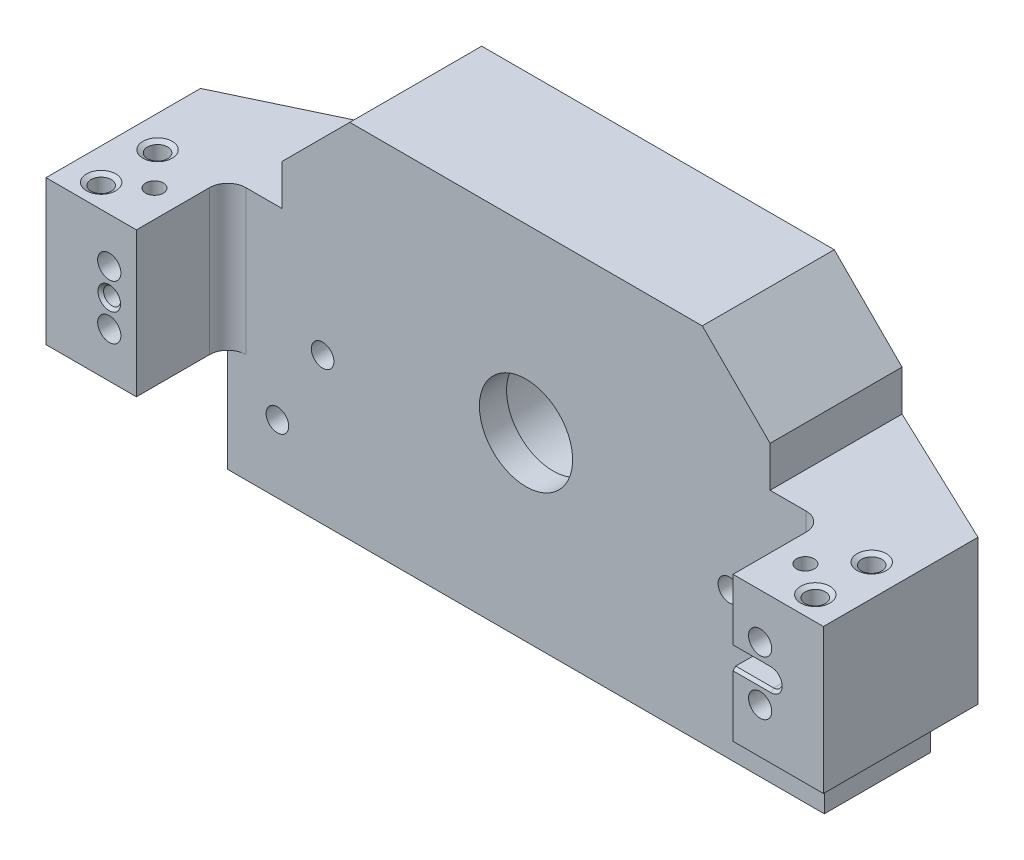
from build123d import *

# Parameters (mm, degrees)
EXTRUDE1_DEPTH                                 = 20.32
EXTRUDE2_DEPTH                                 = 20.32
SKETCH24_W                                     = 68.58
SKETCH24_H                                     = 18.542
EXTRUDE3_DEPTH                                 = 15.24
EXTRUDE4_DEPTH                                 = 15.24
SKETCH38_R                                     = 17.78
SPHERICAL_WASHER_CENTER_RELIEF_DEPTH           = 0.762
TAPPED_HOLE_FOR_1_4_20_HELICOIL_AT_2_COUNT     = 2
TAPPED_HOLE_FOR_1_4_20_HELICOIL_AT_2_PITCH     = 57.15
SKETCH30_R                                     = 1.59512
PIN_SLOT_HOLES_DEPTH                           = 9.525
F_4_CLEARANCE_HOLE1_D                          = 3.175
F_4_CLEARANCE_HOLE2_D                          = 3.175
CBORE_FOR_4_SOCKET_HEAD_CAP_SCREW1_D           = 3.2639
CBORE_FOR_4_SOCKET_HEAD_CAP_SCREW1_CBORE_D     = 5.9436
CBORE_FOR_4_SOCKET_HEAD_CAP_SCREW1_CBORE_DEPTH = 18.2372
F_40_0_098_DIAMETER_HOLE0_D                    = 2.4892
F_4_40_TAPPED_HOLE1_AT_2_COUNT                 = 2
F_4_40_TAPPED_HOLE1_AT_2_PITCH                 = 7.9248
F_4_40_TAPPED_HOLE1_AT_3_COUNT                 = 2
F_4_40_TAPPED_HOLE1_AT_3_PITCH                 = 100.64249279
F_4_40_TAPPED_HOLE1_AT_4_COUNT                 = 2
F_4_40_TAPPED_HOLE1_AT_4_PITCH                 = 100.33
CHAMFER1_SIZE                                  = 9.525
FILLET1_R                                      = 2.54
CHAMFER2_SIZE                                  = 0.9906
F_4_CLEARANCE_HOLE3_D                          = 2.3876
F_4_CLEARANCE_HOLE3_DEPTH                      = 6.35
F_4_CLEARANCE_HOLE3_CSINK_D                    = 3.175
F_4_CLEARANCE_HOLE3_CSINK_ANGLE                = 90
F_4_CLEARANCE_HOLE3_TIP                        = 0.717307407
EXTRUDE5_DEPTH                                 = 6.35
CHAMFER3_SIZE                                  = 0.381


with BuildPart() as part:
    # Sketch2 → Extrude1 (new body)
    with BuildSketch(Plane(origin=(0, 0, 0), x_dir=(1, 0, 0), z_dir=(0, 1, 0))):
        Polygon((-54.61, -12.7), (-54.61, 9.017), (-34.29, 9.017), (-34.29, 18.669), (34.29, 18.669), (34.29, 9.017), (54.61, 9.017), (54.61, -12.7), (41.91, -12.7), (41.91, 0.127), (-41.91, 0.127), (-41.91, -12.7), align=None)
    extrude(amount=EXTRUDE1_DEPTH)

    # Sketch19 → Extrude2 (add)
    with BuildSketch(Plane(origin=(0, 20.32, 0), x_dir=(1, 0, 0), z_dir=(0, 1, 0))):
        Polygon((54.61, 9.017), (34.29, 9.017), (34.29, 18.669), align=None)
        Polygon((-34.29, 18.669), (-34.29, 9.017), (-54.61, 9.017), align=None)
    extrude(amount=-EXTRUDE2_DEPTH)

    # Sketch24 → Extrude3 (add)
    with BuildSketch(Plane(origin=(0, 20.32, 0), x_dir=(1, 0, 0), z_dir=(0, 1, 0))):
        with Locations((0, 9.398)):
            Rectangle(SKETCH24_W, SKETCH24_H)
    extrude(amount=EXTRUDE3_DEPTH)

    # Sketch25 → Extrude4 (add)
    with BuildSketch(Plane.XZ):
        Polygon((-34.29, -18.669), (34.29, -18.669), (41.91, -15.0495), (41.91, -0.127), (-41.91, -0.127), (-41.91, -15.0495), align=None)
    extrude(amount=EXTRUDE4_DEPTH)

    # Sketch38 → Spherical washer Center Relief (cut)
    with BuildSketch(Plane(origin=(0, 0, -18.669), x_dir=(-1, 0, 0), z_dir=(0, 0, -1))):
        with Locations((0, 10.16)):
            Circle(SKETCH38_R)
    extrude(amount=-SPHERICAL_WASHER_CENTER_RELIEF_DEPTH, mode=Mode.SUBTRACT)

    # Sketch26 → Tapped Hole For 1/4-20 Helicoil (revolve, cut)
    with BuildSketch(Plane(origin=(28.575, -15.24, -6.35), x_dir=(0, 0, -1), z_dir=(1, 0, 0))):
        Polygon((0, 0), (0, 22.603827343), (3.3782, 20.574), (3.3782, 11.684), (4.04749, 11.684), (4.04749, 0.01651), (4.064, 0), align=None)
    tapped_hole_for_1_4_20_helicoil = revolve(axis=Axis((28.575, -21.59, -6.35), (0, 1, 0)), mode=Mode.SUBTRACT)

    # Tapped Hole For 1/4-20 Helicoil at 2: Tapped Hole For 1/4-20 Helicoil ×2
    with Locations(*[(-i * TAPPED_HOLE_FOR_1_4_20_HELICOIL_AT_2_PITCH, 0, 0) for i in range(1, TAPPED_HOLE_FOR_1_4_20_HELICOIL_AT_2_COUNT)]):
        add(tapped_hole_for_1_4_20_helicoil, mode=Mode.SUBTRACT)

    # Sketch30 → Pin & Slot Holes (cut)
    with BuildSketch(Plane.XZ.offset(15.24)):
        with Locations(Location((34.925, -13.97, 0), (0, 0, 270))):  # turned: the seam where the file's is
            Circle(SKETCH30_R)
        with BuildLine():
            Line((-33.3375, -15.56512), (-36.5125, -15.56512))
            ThreePointArc((-36.5125, -15.56512), (-38.10762, -13.97), (-36.5125, -12.37488))
            Line((-36.5125, -12.37488), (-33.3375, -12.37488))
            ThreePointArc((-33.3375, -12.37488), (-31.74238, -13.97), (-33.3375, -15.56512))
        make_face()
    extrude(amount=-PIN_SLOT_HOLES_DEPTH, mode=Mode.SUBTRACT)

    # #4 Clearance Hole1 (through all)
    with Locations(Plane(origin=(0, 0, -18.669), x_dir=(-1, 0, 0), z_dir=(0, 0, -1))):
        with Locations((-28.575, 5.334), (28.575, 5.334)):
            Hole(F_4_CLEARANCE_HOLE1_D / 2)

    # #4 Clearance Hole2 (through all)
    with Locations(Plane(origin=(0, 0, -18.669), x_dir=(-1, 0, 0), z_dir=(0, 0, -1))):
        with Locations((-34.925, -5.715), (34.925, -5.715)):
            Hole(F_4_CLEARANCE_HOLE2_D / 2)

    # CBORE for #4 Socket Head Cap Screw1 (through all)
    with Locations(Plane(origin=(-10.402382087, -1.81948853, -18.669), x_dir=(-1, 0, 0), z_dir=(0, 0, -1))):
        with Locations((35.317617913, 8.16948853), (35.317617913, 15.78948853), (-56.122382087, 8.16948853), (-56.122382087, 15.78948853)):
            CounterBoreHole(CBORE_FOR_4_SOCKET_HEAD_CAP_SCREW1_D / 2, CBORE_FOR_4_SOCKET_HEAD_CAP_SCREW1_CBORE_D / 2, CBORE_FOR_4_SOCKET_HEAD_CAP_SCREW1_CBORE_DEPTH)

    # Sketch22 → Tapped Hole for 1/2-13  Helicoil1 (revolve, cut)
    with BuildSketch(Plane(origin=(0, 10.16, -18.669), x_dir=(0, 1, 0), z_dir=(1, 0, 0))):
        Polygon((0, 0), (0, 31.369), (8.30834, 31.369), (6.54812, 30.352736509), (6.54812, 14.732), (7.67334, 14.732), (7.67334, 0.366617421), (8.30834, 0), align=None)
    revolve(axis=Axis((0, 10.16, -25.019), (0, 0, 1)), mode=Mode.SUBTRACT)

    # #40 (0.098) Diameter Hole0 (through all)
    with Locations(Plane(origin=(0, 20.32, 0), x_dir=(-1, 0, 0), z_dir=(0, 1, 0))):
        with Locations((45.72, 6.35), (-45.72, 6.35)):
            Hole(F_40_0_098_DIAMETER_HOLE0_D / 2)

    # Sketch20 → #4-40 Tapped Hole1 (revolve, cut)
    with BuildSketch(Plane(origin=(-50.165, 20.32, 9.398), x_dir=(0, 0, 1), z_dir=(1, 0, 0))):
        Polygon((0, 0), (0, 20.32), (2.0574, 20.32), (1.4224, 19.953382579), (1.4224, 0.366617421), (2.0574, 0), align=None)
    f_4_40_tapped_hole1 = revolve(axis=Axis((-50.165, 26.67, 9.398), (0, -1, 0)), mode=Mode.SUBTRACT)

    # #4-40 Tapped Hole1 at 2: #4-40 Tapped Hole1 ×2
    with Locations(*[(0, 0, -i * F_4_40_TAPPED_HOLE1_AT_2_PITCH) for i in range(1, F_4_40_TAPPED_HOLE1_AT_2_COUNT)]):
        add(f_4_40_tapped_hole1, mode=Mode.SUBTRACT)

    # #4-40 Tapped Hole1 at 3: #4-40 Tapped Hole1 ×2
    with Locations(*[Vector(0.996895021, 0, -0.078742088) * (i * F_4_40_TAPPED_HOLE1_AT_3_PITCH) for i in range(1, F_4_40_TAPPED_HOLE1_AT_3_COUNT)]):
        add(f_4_40_tapped_hole1, mode=Mode.SUBTRACT)

    # #4-40 Tapped Hole1 at 4: #4-40 Tapped Hole1 ×2
    with Locations(*[(i * F_4_40_TAPPED_HOLE1_AT_4_PITCH, 0, 0) for i in range(1, F_4_40_TAPPED_HOLE1_AT_4_COUNT)]):
        add(f_4_40_tapped_hole1, mode=Mode.SUBTRACT)

    # Chamfer1
    chamfer1_edges = [part.edges().sort_by_distance(p)[0] for p in [
        (34.29, 35.56, -9.398),
        (-34.29, 35.56, -9.398),
    ]]
    chamfer(chamfer1_edges, length=CHAMFER1_SIZE)

    # Fillet1
    fillet1_edges = [part.edges().sort_by_distance(p)[0] for p in [
        (-41.91, 10.16, -0.127),
        (41.91, 10.16, -0.127),
    ]]
    fillet(fillet1_edges, radius=FILLET1_R)

    # Chamfer2
    chamfer2_edges = [part.edges().sort_by_distance(p)[0] for p in [
        (34.925, -15.24, -12.37488),
        (-31.74238, -15.24, -13.97),
        (-34.925, -15.24, -12.37488),
        (-38.10762, -15.24, -13.97),
        (-34.925, -15.24, -15.56512),
    ]]
    chamfer(chamfer2_edges, length=CHAMFER2_SIZE)

    # #4 Clearance Hole3
    with Locations(Plane.XY.offset(12.7)):
        with Locations((-45.72, 10.16)):
            CounterSinkHole(F_4_CLEARANCE_HOLE3_D / 2, F_4_CLEARANCE_HOLE3_CSINK_D / 2, depth=F_4_CLEARANCE_HOLE3_DEPTH, counter_sink_angle=F_4_CLEARANCE_HOLE3_CSINK_ANGLE)
            with Locations((0, 0, -(F_4_CLEARANCE_HOLE3_DEPTH + F_4_CLEARANCE_HOLE3_TIP / 2))):  # 118° drill point
                Cone(0, F_4_CLEARANCE_HOLE3_D / 2, F_4_CLEARANCE_HOLE3_TIP, mode=Mode.SUBTRACT)

    # Sketch44 → Extrude5 (cut)
    with BuildSketch(Plane.XY.offset(12.7)):
        with BuildLine():
            Line((41.91, 11.3538), (47.244, 11.3538))
            ThreePointArc((47.244, 11.3538), (48.4378, 10.16), (47.244, 8.9662))
            Line((47.244, 8.9662), (41.91, 8.9662))
            Line((41.91, 8.9662), (41.91, 11.3538))
        make_face()
    extrude(amount=-EXTRUDE5_DEPTH, mode=Mode.SUBTRACT)

    # Chamfer3
    chamfer3_edges = [part.edges().sort_by_distance(p)[0] for p in [
        (44.577, 8.9662, 12.7),
        (48.4378, 10.16, 12.7),
        (44.577, 11.3538, 12.7),
    ]]
    chamfer(chamfer3_edges, length=CHAMFER3_SIZE)


solid = part.part
